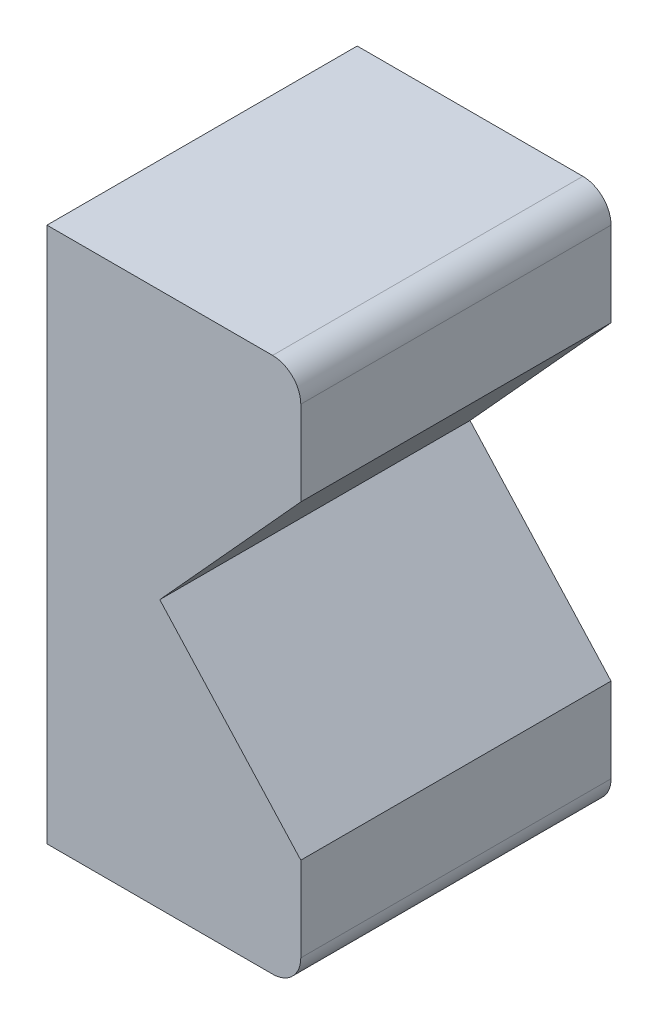
from build123d import *

# Parameters (mm, degrees)
EXTRUDE_1_DEPTH = 11


with BuildPart() as part:
    # Эскиз1 → Бобышка-Вытянуть1 (new body)
    with BuildSketch(Plane.XY):
        with BuildLine():
            Line((0, 0), (0, 19))
            Line((0, 19), (8, 19))
            ThreePointArc((8, 19), (8.707106781, 18.707106781), (9, 18))
            Line((9, 18), (9, 15))
            Line((9, 15), (4, 9.5))
            Line((4, 9.5), (9, 4))
            Line((9, 4), (9, 1))
            ThreePointArc((9, 1), (8.707106781, 0.292893219), (8, 0))
            Line((8, 0), (0, 0))
        make_face()
    extrude(amount=EXTRUDE_1_DEPTH)


solid = part.part
